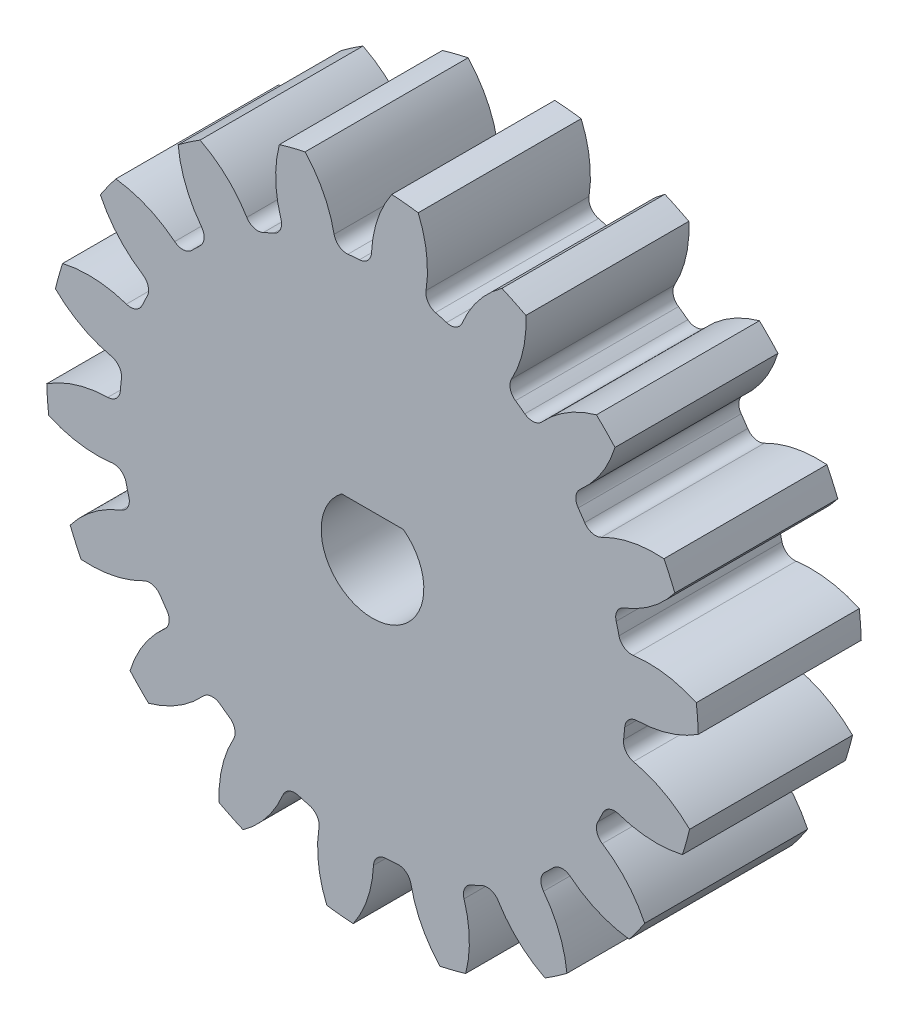
from build123d import *

# Parameters (mm, degrees)
SKETCH3_R         = 12.7
GEARBODY_DEPTH    = 6.35
TOOTHCUT_DEPTH    = 7.35
CIRPATTERN1_COUNT = 18
BORE_DEPTH        = 12.7


with BuildPart() as part:
    # Sketch3 → gearBody (new body)
    with BuildSketch(Plane.XY):
        Circle(SKETCH3_R)
    extrude(amount=GEARBODY_DEPTH)

    # Sketch2 → toothCut (cut, through all)
    with BuildSketch(Plane.XY):
        with BuildLine():
            ThreePointArc((9.781229257, -1.205205904), (9.806057787, -0.982953571), (9.825836884, -0.760195085))
            ThreePointArc((9.825836884, -0.760195085), (9.980803767, -0.435792976), (10.31355819, -0.299682883))
            ThreePointArc((10.31355819, -0.299682883), (12.38209996, 0.246018063), (13.970369973, 1.679214819))
            ThreePointArc((13.970369973, 1.679214819), (14.000763839, -1.403428484), (13.359117821, -4.418706897))
            ThreePointArc((13.359117821, -4.418706897), (12.0869153, -2.698778026), (10.167842346, -1.753360882))
            ThreePointArc((10.167842346, -1.753360882), (9.868724138, -1.553912241), (9.781229257, -1.205205904))
        make_face()
    toothcut = extrude(amount=TOOTHCUT_DEPTH, mode=Mode.SUBTRACT)

    # CirPattern1: toothCut ×18 about axis
    cirpattern1_axis = Axis((0, 0, 0), (0, 0, 1))
    for i in range(1, CIRPATTERN1_COUNT):
        add(toothcut.rotate(cirpattern1_axis, i * 360 / CIRPATTERN1_COUNT), mode=Mode.SUBTRACT)

    # boreDia → bore (cut, symmetric)
    with BuildSketch(Plane.XY):
        with BuildLine():
            Line((-1.2, 1.60000008), (1.2, 1.60000008))
            ThreePointArc((1.2, 1.60000008), (0, -2.000000064), (-1.2, 1.60000008))
        make_face()
    extrude(amount=BORE_DEPTH, both=True, mode=Mode.SUBTRACT)


solid = part.part
